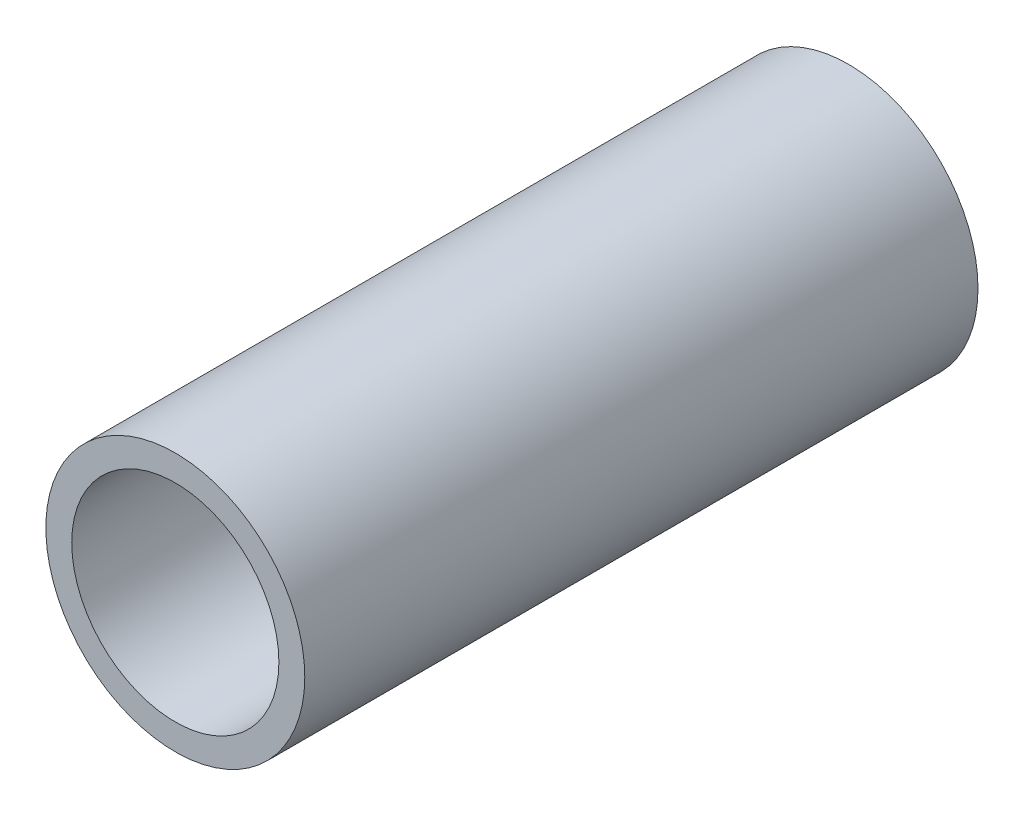
from build123d import *

# Parameters (mm, degrees)
SKETCH1_R           = 2.5
BOSS_EXTRUDE1_DEPTH = 13
SKETCH2_R           = 2
CUT_EXTRUDE1_DEPTH  = 14


with BuildPart() as part:
    # Sketch1 → Boss-Extrude1 (new body)
    with BuildSketch(Plane.XY):
        Circle(SKETCH1_R)
    extrude(amount=BOSS_EXTRUDE1_DEPTH)

    # Sketch2 → Cut-Extrude1 (cut, through all)
    with BuildSketch(Plane.XY.offset(13)):
        Circle(SKETCH2_R)
    extrude(amount=-CUT_EXTRUDE1_DEPTH, mode=Mode.SUBTRACT)


solid = part.part
